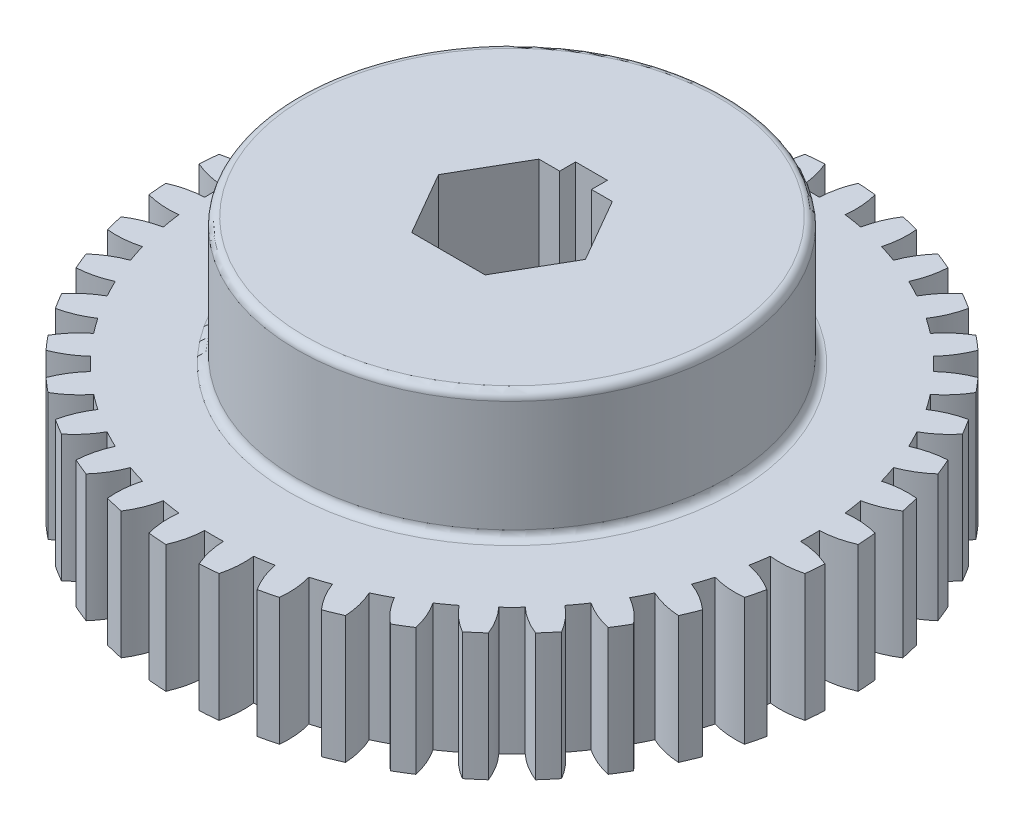
from build123d import *

# Parameters (mm, degrees)
SKETCH1_R           = 29.765625
BOSS_EXTRUDE1_DEPTH = 12.7
SKETCH2_R           = 21.43125
BOSS_EXTRUDE2_DEPTH = 12.7
BOSS_EXTRUDE3_DEPTH = 12.7
CIRPATTERN1_COUNT   = 40
FILLET1_R           = 0.79375
SKETCH6_W           = 3.175
SKETCH6_H           = 7.9375
CUT_EXTRUDE1_DEPTH  = 25.4


with BuildPart() as part:
    # Sketch1 → Boss-Extrude1 (new body)
    with BuildSketch(Plane(origin=(0, 0, 0), x_dir=(1, 0, 0), z_dir=(0, 1, 0))):
        Circle(SKETCH1_R)
        Polygon((7.332348419, 0), (3.666174209, 6.35), (-3.666174209, 6.35), (-7.332348419, 0), (-3.666174209, -6.35), (3.666174209, -6.35), align=None, mode=Mode.SUBTRACT)
    extrude(amount=BOSS_EXTRUDE1_DEPTH)

    # Sketch2 → Boss-Extrude2 (add)
    with BuildSketch(Plane(origin=(0, 12.7, 0), x_dir=(1, 0, 0), z_dir=(0, 1, 0))):
        Circle(SKETCH2_R)
        Polygon((7.332348419, 0), (3.666174209, 6.35), (-3.666174209, 6.35), (-7.332348419, 0), (-3.666174209, -6.35), (3.666174209, -6.35), align=None, mode=Mode.SUBTRACT)
    extrude(amount=BOSS_EXTRUDE2_DEPTH)

    # Sketch5 → Boss-Extrude3 (add)
    with BuildSketch(Plane(origin=(0, 0, 0), x_dir=(1, 0, 0), z_dir=(0, 1, 0))):
        with BuildLine():
            ThreePointArc((3.730622029, 29.530914156), (2.335384021, 29.673867512), (0.934960876, 29.750937461))
            ThreePointArc((0.934960876, 29.750937461), (1.152234502, 31.359212214), (1.666563066, 32.898439825))
            ThreePointArc((1.666563066, 32.898439825), (2.58449165, 32.839080047), (3.500404924, 32.754113341))
            ThreePointArc((3.500404924, 32.754113341), (3.767613002, 31.153377462), (3.730622029, 29.530914156))
        make_face()
    boss_extrude3 = extrude(amount=BOSS_EXTRUDE3_DEPTH)

    # CirPattern1: Boss-Extrude3 ×40 about axis
    cirpattern1_axis = Axis((0, 0, 0), (0, 1, 0))
    for i in range(1, CIRPATTERN1_COUNT):
        add(boss_extrude3.rotate(cirpattern1_axis, i * 360 / CIRPATTERN1_COUNT))

    # Fillet1
    fillet1_edges = [part.edges().sort_by_distance(p)[0] for p in [
        (-21.43125, 12.7, 0),
        (-21.43125, 25.4, 0),
    ]]
    fillet(fillet1_edges, radius=FILLET1_R)

    # Sketch6 → Cut-Extrude1 (cut)
    with BuildSketch(Plane(origin=(0, 25.4, 0), x_dir=(1, 0, 0), z_dir=(0, 1, 0))):
        with Locations((0, 3.96875)):
            Rectangle(SKETCH6_W, SKETCH6_H)
    extrude(amount=-CUT_EXTRUDE1_DEPTH, mode=Mode.SUBTRACT)


solid = part.part
